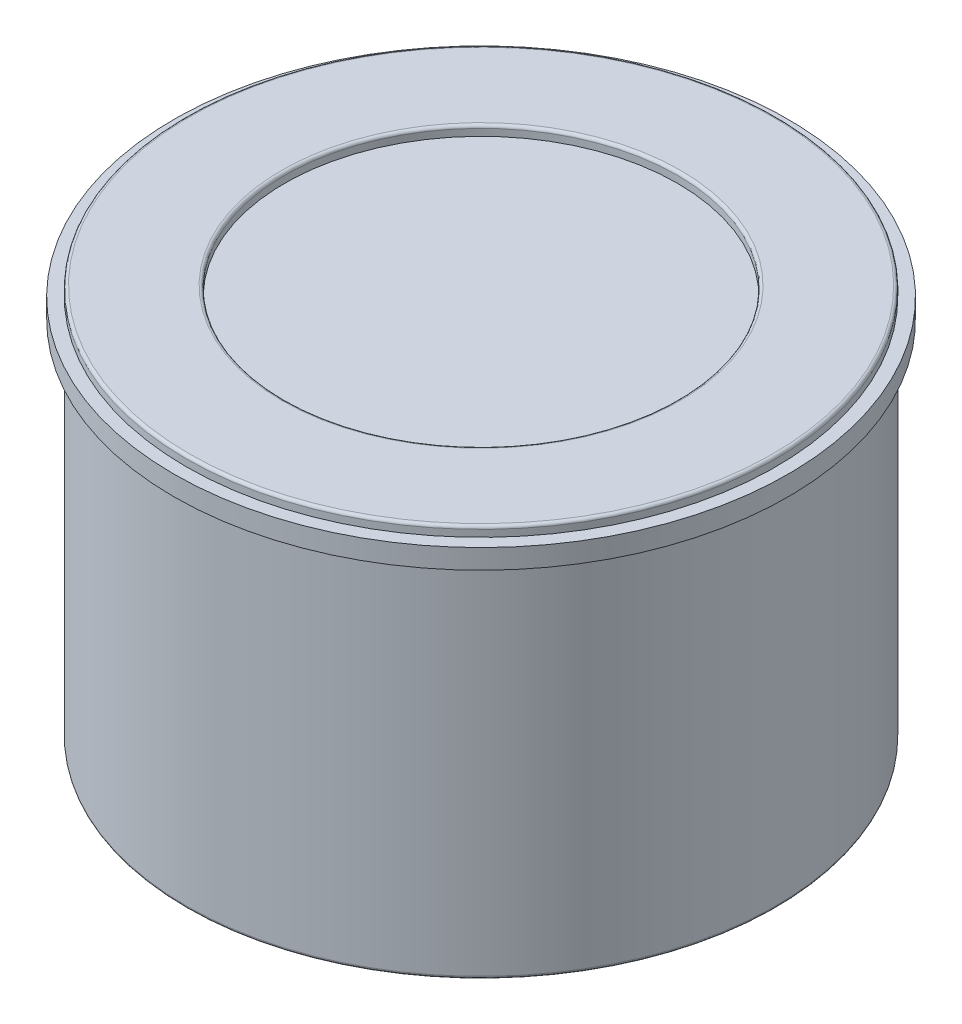
from build123d import *

# Parameters (mm, degrees)
IZIM1_R                     = 15
Y_KSEKLIK_EKSTR_ZYON2_DEPTH = 20
IZIM2_R                     = 10
KES_EKSTR_ZYON1_DEPTH       = 1
IZIM3_R                     = 10
KES_EKSTR_ZYON2_DEPTH       = 3
IZIM4_W                     = 4
IZIM4_H                     = 4
Y_KSEKLIK_EKSTR_ZYON3_DEPTH = 7
KES_EKSTR_ZYON3_DEPTH       = 7
RADYUS1_R                   = 0.15
Y_KSEKLIK_EKSTR_ZYON4_START = -0.5
IZIM6_R                     = 15.636710187
Y_KSEKLIK_EKSTR_ZYON4_DEPTH = 1


with BuildPart() as part:
    # Çizim1 → Yükseklik-Ekstrüzyon2 (new body)
    with BuildSketch(Plane(origin=(0, 0, 0), x_dir=(1, 0, 0), z_dir=(0, 1, 0))):
        Circle(IZIM1_R)
    extrude(amount=Y_KSEKLIK_EKSTR_ZYON2_DEPTH)

    # Çizim2 → Kes-Ekstrüzyon1 (cut)
    with BuildSketch(Plane(origin=(0, 20, 0), x_dir=(1, 0, 0), z_dir=(0, 1, 0))):
        Circle(IZIM2_R)
    extrude(amount=-KES_EKSTR_ZYON1_DEPTH, mode=Mode.SUBTRACT)

    # Çizim3 → Kes-Ekstrüzyon2 (cut)
    with BuildSketch(Plane.XZ):
        Circle(IZIM3_R)
    extrude(amount=-KES_EKSTR_ZYON2_DEPTH, mode=Mode.SUBTRACT)

    # Çizim4 → Yükseklik-Ekstrüzyon3 (add)
    with BuildSketch(Plane.XZ.offset(-3)):
        Rectangle(IZIM4_W, IZIM4_H)
    extrude(amount=Y_KSEKLIK_EKSTR_ZYON3_DEPTH)

    # Çizim5 → Kes-Ekstrüzyon3 (cut)
    with BuildSketch(Plane(origin=(2, 0, 0), x_dir=(0, 0, -1), z_dir=(1, 0, 0))):
        with BuildLine():
            ThreePointArc((1.060660172, -0.939339828), (-1.060660172, -0.939339828), (-1.060660172, -3.060660172))
            Line((-1.060660172, -3.060660172), (1.060660172, -0.939339828))
        make_face()
        with BuildLine():
            Line((1.060660172, -0.939339828), (-1.060660172, -3.060660172))
            ThreePointArc((-1.060660172, -3.060660172), (0.574025149, -3.385819299), (1.5, -2))
            ThreePointArc((1.5, -2), (1.385819299, -1.425974851), (1.060660172, -0.939339828))
        make_face()
    extrude(amount=-KES_EKSTR_ZYON3_DEPTH, mode=Mode.SUBTRACT)

    # Radyus1
    radyus1_edges = [part.edges().sort_by_distance(p)[0] for p in [
        (-10, 0, 0),
        (0, -4, 2),
        (0, -4, -2),
        (-15, 0, 0),
        (-15, 20, 0),
        (-10, 20, 0),
    ]]
    fillet(radyus1_edges, radius=RADYUS1_R)

    # Çizim6 → Yükseklik-Ekstrüzyon4 (add)
    with BuildSketch(Plane(origin=(0, 20, 0), x_dir=(1, 0, 0), z_dir=(0, 1, 0)).offset(Y_KSEKLIK_EKSTR_ZYON4_START)):
        Circle(IZIM6_R)
    extrude(amount=-Y_KSEKLIK_EKSTR_ZYON4_DEPTH)


solid = part.part
